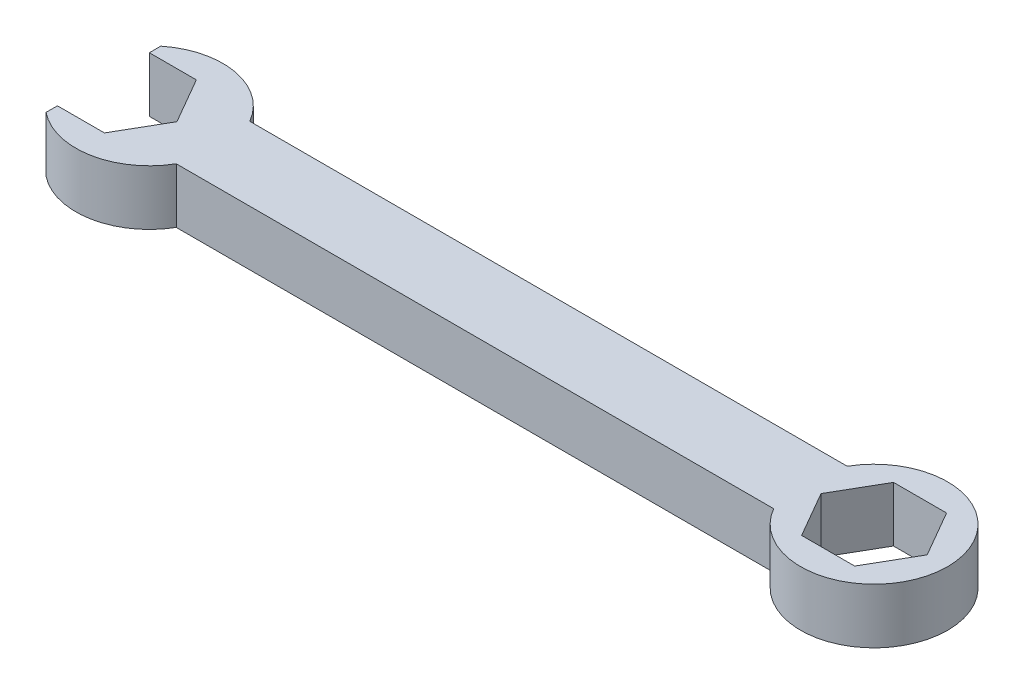
from build123d import *

# Parameters (mm, degrees)
SKETCH1_R           = 10.16
BOSS_EXTRUDE1_DEPTH = 7.62


with BuildPart() as part:
    # Sketch1 → Boss-Extrude1 (new body)
    with BuildSketch(Plane(origin=(0, 0, 0), x_dir=(1, 0, 0), z_dir=(0, 1, 0))):
        Circle(SKETCH1_R)
        Polygon((3.666174209, -6.35), (7.332348419, 0), (3.666174209, 6.35), (-3.666174209, 6.35), (-7.332348419, 0), (-3.666174209, -6.35), align=None, mode=Mode.SUBTRACT)
        with BuildLine():
            Line((-8.798818102, 5.08), (-91.348818102, 5.08))
            ThreePointArc((-91.348818102, 5.08), (-90.33382981, 2.629601498), (-89.987636205, 0))
            ThreePointArc((-89.987636205, 0), (-90.33382981, -2.629601498), (-91.348818102, -5.08))
            Line((-91.348818102, -5.08), (-8.798818102, -5.08))
            ThreePointArc((-8.798818102, -5.08), (-10.16, 0), (-8.798818102, 5.08))
        make_face()
        with BuildLine():
            ThreePointArc((-89.987636205, 0), (-90.33382981, 2.629601498), (-91.348818102, 5.08))
            ThreePointArc((-91.348818102, 5.08), (-98.268424141, 9.984696391), (-106.497636205, 7.931147458))
            Line((-106.497636205, 7.931147458), (-106.497636205, 6.35))
            Line((-106.497636205, 6.35), (-100.003810414, 6.35))
            Line((-100.003810414, 6.35), (-96.337636205, 0))
            Line((-96.337636205, 0), (-100.003810414, -6.35))
            Line((-100.003810414, -6.35), (-106.497636205, -6.35))
            Line((-106.497636205, -6.35), (-106.497636205, -7.931147458))
            ThreePointArc((-106.497636205, -7.931147458), (-98.268424141, -9.984696391), (-91.348818102, -5.08))
            ThreePointArc((-91.348818102, -5.08), (-90.33382981, -2.629601498), (-89.987636205, 0))
        make_face()
    extrude(amount=BOSS_EXTRUDE1_DEPTH)


solid = part.part
